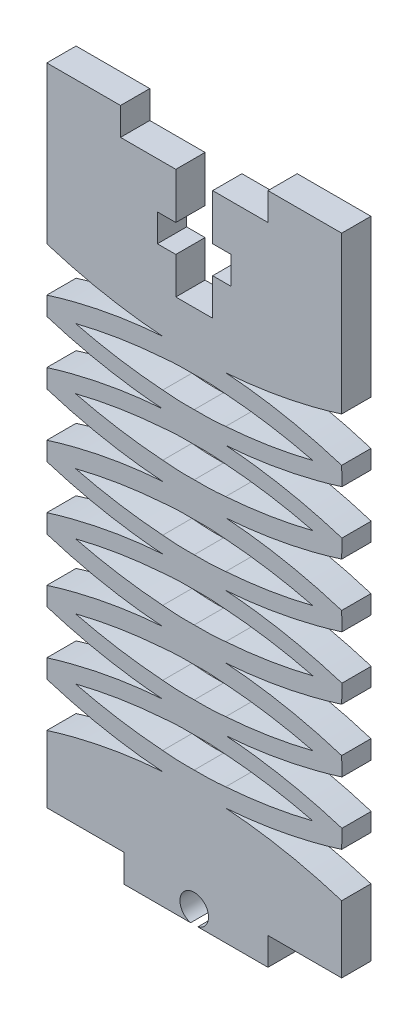
from build123d import *

# Parameters (mm, degrees)
BOSS_EXTRUDE1_DEPTH = 3.175


with BuildPart() as part:
    # Sketch1 → Boss-Extrude1 (new body)
    with BuildSketch(Plane.XY):
        with BuildLine():
            Line((0, 0), (8.370325746, 0))
            Line((8.370325746, 0), (8.370325746, -3))
            Line((8.370325746, -3), (15.609487516, -3))
            ThreePointArc((15.609487516, -3), (16, 0.05), (16.390512484, -3))
            Line((16.390512484, -3), (24, -3))
            Line((24, -3), (24, 0))
            Line((24, 0), (32, 0))
            Line((32, 0), (32, 5.370178283))
            Line((32, 5.370178283), (32, 7.265547887))
            add(Edge.make_bspline(
                [(32, 7.265547887), (27.898501415, 8.558072428), (23.69150053, 9.361273689), (19.417459256, 9.67515167)],
                knots=[0, 0, 0, 0, 0.790279221, 0.790279221, 0.790279221, 0.790279221], degree=3))
            add(Edge.make_bspline(
                [(32, 12.084755453), (27.898501415, 10.792230912), (23.69150053, 9.98902965), (19.417459256, 9.67515167)],
                knots=[0, 0, 0, 0, 0.790279221, 0.790279221, 0.790279221, 0.790279221], degree=3))
            Line((32, 12.084755453), (32.028943123, 14.084755311))
            add(Edge.make_bspline(
                [(32.028943123, 14.084755311), (27.89482684, 15.377279852), (23.690748061, 16.180481113), (19.416706786, 16.494359094)],
                knots=[0, 0, 0, 0, 0.790279221, 0.790279221, 0.790279221, 0.790279221], degree=3))
            add(Edge.make_bspline(
                [(32.028943123, 18.903962877), (27.89482684, 17.611438336), (23.690748061, 16.808237075), (19.416706786, 16.494359094)],
                knots=[0, 0, 0, 0, 0.790279221, 0.790279221, 0.790279221, 0.790279221], degree=3))
            Line((32.028943123, 18.903962877), (32, 20.903962736))
            add(Edge.make_bspline(
                [(32, 20.903962736), (27.898501415, 22.196487277), (23.69150053, 22.999688538), (19.417459256, 23.313566519)],
                knots=[0, 0, 0, 0, 0.790279221, 0.790279221, 0.790279221, 0.790279221], degree=3))
            add(Edge.make_bspline(
                [(32, 25.723170302), (27.898501415, 24.430645761), (23.69150053, 23.6274445), (19.417459256, 23.313566519)],
                knots=[0, 0, 0, 0, 0.790279221, 0.790279221, 0.790279221, 0.790279221], degree=3))
            Line((32, 25.723170302), (32.028943123, 27.72317016))
            add(Edge.make_bspline(
                [(32.028943123, 27.72317016), (27.89482684, 29.015694701), (23.690748061, 29.818895962), (19.416706786, 30.132773943)],
                knots=[0, 0, 0, 0, 0.790279221, 0.790279221, 0.790279221, 0.790279221], degree=3))
            add(Edge.make_bspline(
                [(32.028943123, 32.542377726), (27.89482684, 31.249853185), (23.690748061, 30.446651924), (19.416706786, 30.132773943)],
                knots=[0, 0, 0, 0, 0.790279221, 0.790279221, 0.790279221, 0.790279221], degree=3))
            Line((32.028943123, 32.542377726), (32, 34.542377585))
            add(Edge.make_bspline(
                [(32, 34.542377585), (27.898501415, 35.834902126), (23.69150053, 36.638103387), (19.417459256, 36.951981368)],
                knots=[0, 0, 0, 0, 0.790279221, 0.790279221, 0.790279221, 0.790279221], degree=3))
            add(Edge.make_bspline(
                [(32, 39.361585151), (27.898501415, 38.06906061), (23.69150053, 37.265859349), (19.417459256, 36.951981368)],
                knots=[0, 0, 0, 0, 0.790279221, 0.790279221, 0.790279221, 0.790279221], degree=3))
            Line((32, 39.361585151), (32.028943123, 41.361585009))
            add(Edge.make_bspline(
                [(32.028943123, 41.361585009), (27.89482684, 42.65410955), (23.690748061, 43.457310811), (19.416706786, 43.771188792)],
                knots=[0, 0, 0, 0, 0.790279221, 0.790279221, 0.790279221, 0.790279221], degree=3))
            add(Edge.make_bspline(
                [(32.028943123, 46.180792575), (27.89482684, 44.888268034), (23.690748061, 44.085066773), (19.416706786, 43.771188792)],
                knots=[0, 0, 0, 0, 0.790279221, 0.790279221, 0.790279221, 0.790279221], degree=3))
            Line((32.028943123, 46.180792575), (32, 48.180792434))
            add(Edge.make_bspline(
                [(32, 48.180792434), (27.898501415, 49.473316975), (23.69150053, 50.276518236), (19.417459256, 50.590396217)],
                knots=[0, 0, 0, 0, 0.790279221, 0.790279221, 0.790279221, 0.790279221], degree=3))
            add(Edge.make_bspline(
                [(32, 53), (27.898501415, 51.707475459), (23.69150053, 50.904274198), (19.417459256, 50.590396217)],
                knots=[0, 0, 0, 0, 0.790279221, 0.790279221, 0.790279221, 0.790279221], degree=3))
            Line((32, 53), (32, 70))
            Line((32, 70), (24, 70))
            Line((24, 70), (24, 67))
            Line((24, 67), (18, 67))
            Line((18, 67), (18, 62))
            Line((18, 62), (20, 62))
            Line((20, 62), (20, 59))
            Line((20, 59), (18, 59))
            Line((18, 59), (18, 55))
            Line((18, 55), (14, 55))
            Line((14, 55), (14, 59))
            Line((14, 59), (12, 59))
            Line((12, 59), (12, 62))
            Line((12, 62), (14, 62))
            Line((14, 62), (14, 67))
            Line((14, 67), (8, 67))
            Line((8, 67), (8, 70))
            Line((8, 70), (0, 70))
            Line((0, 70), (0, 53))
            add(Edge.make_bspline(
                [(0, 53), (4.101498585, 51.707475459), (8.30849947, 50.904274198), (12.582540744, 50.590396217)],
                knots=[0, 0, 0, 0, 0.790279221, 0.790279221, 0.790279221, 0.790279221], degree=3))
            add(Edge.make_bspline(
                [(0, 48.180792434), (4.101498585, 49.473316975), (8.30849947, 50.276518236), (12.582540744, 50.590396217)],
                knots=[0, 0, 0, 0, 0.790279221, 0.790279221, 0.790279221, 0.790279221], degree=3))
            Line((0, 48.180792434), (0, 46.171751905))
            add(Edge.make_bspline(
                [(0, 46.171751905), (3.182464098, 45.17859632), (7.360986386, 44.267141319), (11.609145024, 43.842728501), (12.583293214, 43.771188792)],
                knots=[0.001844187, 0.001844187, 0.001844187, 0.001844187, 0.610157172, 0.790279221, 0.790279221, 0.790279221, 0.790279221], degree=3))
            add(Edge.make_bspline(
                [(0, 41.37062568), (3.182464098, 42.363781265), (7.360986386, 43.275236266), (11.609145024, 43.699649084), (12.583293214, 43.771188792)],
                knots=[0.001844187, 0.001844187, 0.001844187, 0.001844187, 0.610157172, 0.790279221, 0.790279221, 0.790279221, 0.790279221], degree=3))
            Line((0, 41.37062568), (0, 39.361585151))
            add(Edge.make_bspline(
                [(0, 39.361585151), (4.101498585, 38.06906061), (8.30849947, 37.265859349), (12.582540744, 36.951981368)],
                knots=[0, 0, 0, 0, 0.790279221, 0.790279221, 0.790279221, 0.790279221], degree=3))
            add(Edge.make_bspline(
                [(0, 34.542377585), (4.101498585, 35.834902126), (8.30849947, 36.638103387), (12.582540744, 36.951981368)],
                knots=[0, 0, 0, 0, 0.790279221, 0.790279221, 0.790279221, 0.790279221], degree=3))
            Line((0, 34.542377585), (0, 32.533337056))
            add(Edge.make_bspline(
                [(0, 32.533337056), (3.182464098, 31.540181471), (7.360986386, 30.62872647), (11.609145024, 30.204313652), (12.583293214, 30.132773943)],
                knots=[0.001844187, 0.001844187, 0.001844187, 0.001844187, 0.610157172, 0.790279221, 0.790279221, 0.790279221, 0.790279221], degree=3))
            add(Edge.make_bspline(
                [(0, 27.732210831), (3.182464098, 28.725366416), (7.360986386, 29.636821417), (11.609145024, 30.061234235), (12.583293214, 30.132773943)],
                knots=[0.001844187, 0.001844187, 0.001844187, 0.001844187, 0.610157172, 0.790279221, 0.790279221, 0.790279221, 0.790279221], degree=3))
            Line((0, 27.732210831), (0, 25.723170302))
            add(Edge.make_bspline(
                [(0, 25.723170302), (4.101498585, 24.430645761), (8.30849947, 23.6274445), (12.582540744, 23.313566519)],
                knots=[0, 0, 0, 0, 0.790279221, 0.790279221, 0.790279221, 0.790279221], degree=3))
            add(Edge.make_bspline(
                [(0, 20.903962736), (4.101498585, 22.196487277), (8.30849947, 22.999688538), (12.582540744, 23.313566519)],
                knots=[0, 0, 0, 0, 0.790279221, 0.790279221, 0.790279221, 0.790279221], degree=3))
            Line((0, 20.903962736), (0, 18.894922207))
            add(Edge.make_bspline(
                [(0, 18.894922207), (3.182464098, 17.901766622), (7.360986386, 16.990311621), (11.609145024, 16.565898803), (12.583293214, 16.494359094)],
                knots=[0.001844187, 0.001844187, 0.001844187, 0.001844187, 0.610157172, 0.790279221, 0.790279221, 0.790279221, 0.790279221], degree=3))
            add(Edge.make_bspline(
                [(0, 14.093795982), (3.182464098, 15.086951567), (7.360986386, 15.998406568), (11.609145024, 16.422819386), (12.583293214, 16.494359094)],
                knots=[0.001844187, 0.001844187, 0.001844187, 0.001844187, 0.610157172, 0.790279221, 0.790279221, 0.790279221, 0.790279221], degree=3))
            Line((0, 14.093795982), (0, 12.084755453))
            add(Edge.make_bspline(
                [(0, 12.084755453), (4.101498585, 10.792230912), (8.30849947, 9.98902965), (12.582540744, 9.67515167)],
                knots=[0, 0, 0, 0, 0.790279221, 0.790279221, 0.790279221, 0.790279221], degree=3))
            add(Edge.make_bspline(
                [(0, 7.265547887), (4.101498585, 8.558072428), (8.30849947, 9.361273689), (12.582540744, 9.67515167)],
                knots=[0, 0, 0, 0, 0.790279221, 0.790279221, 0.790279221, 0.790279221], degree=3))
            Line((0, 7.265547887), (0, 0))
        make_face()
        with BuildLine():
            add(Edge.make_bspline(
                [(28.876946835, 47.068047714), (26.712893607, 47.610351012), (23.571390937, 48.20110481), (20.390854976, 48.51885665), (19.416706786, 48.590396358)],
                knots=[0.199989123, 0.199989123, 0.199989123, 0.199989123, 0.610157172, 0.790279221, 0.790279221, 0.790279221, 0.790279221], degree=3))
            add(Edge.make_bspline(
                [(19.416706786, 48.590396358), (17.713334631, 48.76927191), (16, 48.720940231)],
                knots=[0, 0, 0, 1, 1, 1], degree=2))
            add(Edge.make_bspline(
                [(12.583293214, 48.590396358), (14.286665369, 48.76927191), (16, 48.720940231)],
                knots=[0, 0, 0, 1, 1, 1], degree=2))
            add(Edge.make_bspline(
                [(3.123053165, 47.068047714), (5.287106393, 47.610351012), (8.428609063, 48.20110481), (11.609145024, 48.51885665), (12.583293214, 48.590396358)],
                knots=[0.199989123, 0.199989123, 0.199989123, 0.199989123, 0.610157172, 0.790279221, 0.790279221, 0.790279221, 0.790279221], degree=3))
            add(Edge.make_bspline(
                [(3.123053165, 47.068047714), (5.287106393, 46.525744415), (8.428609063, 45.934990617), (11.609145024, 45.617238777), (12.583293214, 45.545699069)],
                knots=[0.199989123, 0.199989123, 0.199989123, 0.199989123, 0.610157172, 0.790279221, 0.790279221, 0.790279221, 0.790279221], degree=3))
            add(Edge.make_bspline(
                [(12.583293214, 45.545699069), (14.286665369, 45.366823517), (16, 45.415155196)],
                knots=[0, 0, 0, 1, 1, 1], degree=2))
            add(Edge.make_bspline(
                [(19.416706786, 45.545699069), (17.713334631, 45.366823517), (16, 45.415155196)],
                knots=[0, 0, 0, 1, 1, 1], degree=2))
            add(Edge.make_bspline(
                [(28.876946835, 47.068047714), (26.712893607, 46.525744415), (23.571390937, 45.934990617), (20.390854976, 45.617238777), (19.416706786, 45.545699069)],
                knots=[0.199989123, 0.199989123, 0.199989123, 0.199989123, 0.610157172, 0.790279221, 0.790279221, 0.790279221, 0.790279221], degree=3))
        make_face(mode=Mode.SUBTRACT)
        with BuildLine():
            add(Edge.make_bspline(
                [(19.416706786, 41.996678516), (17.713334631, 42.175554067), (16, 42.127222389)],
                knots=[0, 0, 0, 1, 1, 1], degree=2))
            add(Edge.make_bspline(
                [(12.583293214, 41.996678516), (14.286665369, 42.175554067), (16, 42.127222389)],
                knots=[0, 0, 0, 1, 1, 1], degree=2))
            add(Edge.make_bspline(
                [(3.123054056, 40.474329642), (5.287107289, 41.016632943), (8.428608859, 41.607387016), (11.609145024, 41.925138808), (12.583293214, 41.996678516)],
                knots=[0.199989122, 0.199989122, 0.199989122, 0.199989122, 0.610157172, 0.790279221, 0.790279221, 0.790279221, 0.790279221], degree=3))
            add(Edge.make_bspline(
                [(3.123054056, 40.474329642), (5.287106992, 39.932026454), (8.428609366, 39.341272746), (11.609145024, 39.023520935), (12.583293214, 38.951981226)],
                knots=[0.199989179, 0.199989179, 0.199989179, 0.199989179, 0.610157172, 0.790279221, 0.790279221, 0.790279221, 0.790279221], degree=3))
            add(Edge.make_bspline(
                [(12.583293214, 38.951981226), (14.286665369, 38.773105675), (16, 38.821437353)],
                knots=[0, 0, 0, 1, 1, 1], degree=2))
            add(Edge.make_bspline(
                [(19.416706786, 38.951981226), (17.713334631, 38.773105675), (16, 38.821437353)],
                knots=[0, 0, 0, 1, 1, 1], degree=2))
            add(Edge.make_bspline(
                [(28.876945944, 40.474329642), (26.712893008, 39.932026454), (23.571390634, 39.341272746), (20.390854976, 39.023520935), (19.416706786, 38.951981226)],
                knots=[0.199989179, 0.199989179, 0.199989179, 0.199989179, 0.610157172, 0.790279221, 0.790279221, 0.790279221, 0.790279221], degree=3))
            add(Edge.make_bspline(
                [(28.876945944, 40.474329642), (26.712892711, 41.016632943), (23.571391141, 41.607387016), (20.390854976, 41.925138808), (19.416706786, 41.996678516)],
                knots=[0.199989122, 0.199989122, 0.199989122, 0.199989122, 0.610157172, 0.790279221, 0.790279221, 0.790279221, 0.790279221], degree=3))
        make_face(mode=Mode.SUBTRACT)
        with BuildLine():
            add(Edge.make_bspline(
                [(19.416706786, 31.90728422), (17.713334631, 31.728408668), (16, 31.776740347)],
                knots=[0, 0, 0, 1, 1, 1], degree=2))
            add(Edge.make_bspline(
                [(12.583293214, 31.90728422), (14.286665369, 31.728408668), (16, 31.776740347)],
                knots=[0, 0, 0, 1, 1, 1], degree=2))
            add(Edge.make_bspline(
                [(3.123054056, 33.429633093), (5.287107289, 32.887329792), (8.428608859, 32.296575719), (11.609145024, 31.978823928), (12.583293214, 31.90728422)],
                knots=[0.199989122, 0.199989122, 0.199989122, 0.199989122, 0.610157172, 0.790279221, 0.790279221, 0.790279221, 0.790279221], degree=3))
            add(Edge.make_bspline(
                [(3.123054056, 33.429633093), (5.287106992, 33.971936281), (8.428609366, 34.56268999), (11.609145024, 34.880441801), (12.583293214, 34.951981509)],
                knots=[0.199989179, 0.199989179, 0.199989179, 0.199989179, 0.610157172, 0.790279221, 0.790279221, 0.790279221, 0.790279221], degree=3))
            add(Edge.make_bspline(
                [(12.583293214, 34.951981509), (14.286665369, 35.130857061), (16, 35.082525382)],
                knots=[0, 0, 0, 1, 1, 1], degree=2))
            add(Edge.make_bspline(
                [(19.416706786, 34.951981509), (17.713334631, 35.130857061), (16, 35.082525382)],
                knots=[0, 0, 0, 1, 1, 1], degree=2))
            add(Edge.make_bspline(
                [(28.876945944, 33.429633093), (26.712893008, 33.971936281), (23.571390634, 34.56268999), (20.390854976, 34.880441801), (19.416706786, 34.951981509)],
                knots=[0.199989179, 0.199989179, 0.199989179, 0.199989179, 0.610157172, 0.790279221, 0.790279221, 0.790279221, 0.790279221], degree=3))
            add(Edge.make_bspline(
                [(28.876945944, 33.429633093), (26.712892711, 32.887329792), (23.571391141, 32.296575719), (20.390854976, 31.978823928), (19.416706786, 31.90728422)],
                knots=[0.199989122, 0.199989122, 0.199989122, 0.199989122, 0.610157172, 0.790279221, 0.790279221, 0.790279221, 0.790279221], degree=3))
        make_face(mode=Mode.SUBTRACT)
        with BuildLine():
            add(Edge.make_bspline(
                [(19.416706786, 28.358263667), (17.713334631, 28.537139218), (16, 28.48880754)],
                knots=[0, 0, 0, 1, 1, 1], degree=2))
            add(Edge.make_bspline(
                [(12.583293214, 28.358263667), (14.286665369, 28.537139218), (16, 28.48880754)],
                knots=[0, 0, 0, 1, 1, 1], degree=2))
            add(Edge.make_bspline(
                [(3.123054056, 26.835914793), (5.287107289, 27.378218094), (8.428608859, 27.968972167), (11.609145024, 28.286723958), (12.583293214, 28.358263667)],
                knots=[0.199989122, 0.199989122, 0.199989122, 0.199989122, 0.610157172, 0.790279221, 0.790279221, 0.790279221, 0.790279221], degree=3))
            add(Edge.make_bspline(
                [(3.123054056, 26.835914793), (5.287106992, 26.293611605), (8.428609366, 25.702857897), (11.609145024, 25.385106086), (12.583293214, 25.313566377)],
                knots=[0.199989179, 0.199989179, 0.199989179, 0.199989179, 0.610157172, 0.790279221, 0.790279221, 0.790279221, 0.790279221], degree=3))
            add(Edge.make_bspline(
                [(12.583293214, 25.313566377), (14.286665369, 25.134690826), (16, 25.183022504)],
                knots=[0, 0, 0, 1, 1, 1], degree=2))
            add(Edge.make_bspline(
                [(19.416706786, 25.313566377), (17.713334631, 25.134690826), (16, 25.183022504)],
                knots=[0, 0, 0, 1, 1, 1], degree=2))
            add(Edge.make_bspline(
                [(28.876945944, 26.835914793), (26.712893008, 26.293611605), (23.571390634, 25.702857897), (20.390854976, 25.385106086), (19.416706786, 25.313566377)],
                knots=[0.199989179, 0.199989179, 0.199989179, 0.199989179, 0.610157172, 0.790279221, 0.790279221, 0.790279221, 0.790279221], degree=3))
            add(Edge.make_bspline(
                [(28.876945944, 26.835914793), (26.712892711, 27.378218094), (23.571391141, 27.968972167), (20.390854976, 28.286723958), (19.416706786, 28.358263667)],
                knots=[0.199989122, 0.199989122, 0.199989122, 0.199989122, 0.610157172, 0.790279221, 0.790279221, 0.790279221, 0.790279221], degree=3))
        make_face(mode=Mode.SUBTRACT)
        with BuildLine():
            add(Edge.make_bspline(
                [(19.416706786, 21.31356666), (17.713334631, 21.492442212), (16, 21.444110533)],
                knots=[0, 0, 0, 1, 1, 1], degree=2))
            add(Edge.make_bspline(
                [(12.583293214, 21.31356666), (14.286665369, 21.492442212), (16, 21.444110533)],
                knots=[0, 0, 0, 1, 1, 1], degree=2))
            add(Edge.make_bspline(
                [(3.123054056, 19.791218244), (5.287106992, 20.333521432), (8.428609366, 20.924275141), (11.609145024, 21.242026952), (12.583293214, 21.31356666)],
                knots=[0.199989179, 0.199989179, 0.199989179, 0.199989179, 0.610157172, 0.790279221, 0.790279221, 0.790279221, 0.790279221], degree=3))
            add(Edge.make_bspline(
                [(3.123054056, 19.791218244), (5.287107289, 19.248914943), (8.428608859, 18.65816087), (11.609145024, 18.340409079), (12.583293214, 18.26886937)],
                knots=[0.199989122, 0.199989122, 0.199989122, 0.199989122, 0.610157172, 0.790279221, 0.790279221, 0.790279221, 0.790279221], degree=3))
            add(Edge.make_bspline(
                [(12.583293214, 18.26886937), (14.286665369, 18.089993819), (16, 18.138325498)],
                knots=[0, 0, 0, 1, 1, 1], degree=2))
            add(Edge.make_bspline(
                [(19.416706786, 18.26886937), (17.713334631, 18.089993819), (16, 18.138325498)],
                knots=[0, 0, 0, 1, 1, 1], degree=2))
            add(Edge.make_bspline(
                [(28.876945944, 19.791218244), (26.712892711, 19.248914943), (23.571391141, 18.65816087), (20.390854976, 18.340409079), (19.416706786, 18.26886937)],
                knots=[0.199989122, 0.199989122, 0.199989122, 0.199989122, 0.610157172, 0.790279221, 0.790279221, 0.790279221, 0.790279221], degree=3))
            add(Edge.make_bspline(
                [(28.876945944, 19.791218244), (26.712893008, 20.333521432), (23.571390634, 20.924275141), (20.390854976, 21.242026952), (19.416706786, 21.31356666)],
                knots=[0.199989179, 0.199989179, 0.199989179, 0.199989179, 0.610157172, 0.790279221, 0.790279221, 0.790279221, 0.790279221], degree=3))
        make_face(mode=Mode.SUBTRACT)
        with BuildLine():
            add(Edge.make_bspline(
                [(3.123054056, 13.197499944), (5.287107289, 13.739803245), (8.428608859, 14.330557318), (11.609145024, 14.648309109), (12.583293214, 14.719848818)],
                knots=[0.199989122, 0.199989122, 0.199989122, 0.199989122, 0.610157172, 0.790279221, 0.790279221, 0.790279221, 0.790279221], degree=3))
            add(Edge.make_bspline(
                [(12.583293214, 14.719848818), (14.286665369, 14.898724369), (16, 14.850392691)],
                knots=[0, 0, 0, 1, 1, 1], degree=2))
            add(Edge.make_bspline(
                [(19.416706786, 14.719848818), (17.713334631, 14.898724369), (16, 14.850392691)],
                knots=[0, 0, 0, 1, 1, 1], degree=2))
            add(Edge.make_bspline(
                [(28.876945944, 13.197499944), (26.712892711, 13.739803245), (23.571391141, 14.330557318), (20.390854976, 14.648309109), (19.416706786, 14.719848818)],
                knots=[0.199989122, 0.199989122, 0.199989122, 0.199989122, 0.610157172, 0.790279221, 0.790279221, 0.790279221, 0.790279221], degree=3))
            add(Edge.make_bspline(
                [(28.876945944, 13.197499944), (26.712893008, 12.655196756), (23.571390634, 12.064443047), (20.390854976, 11.746691237), (19.416706786, 11.675151528)],
                knots=[0.199989179, 0.199989179, 0.199989179, 0.199989179, 0.610157172, 0.790279221, 0.790279221, 0.790279221, 0.790279221], degree=3))
            add(Edge.make_bspline(
                [(19.416706786, 11.675151528), (17.713334631, 11.496275977), (16, 11.544607655)],
                knots=[0, 0, 0, 1, 1, 1], degree=2))
            add(Edge.make_bspline(
                [(12.583293214, 11.675151528), (14.286665369, 11.496275977), (16, 11.544607655)],
                knots=[0, 0, 0, 1, 1, 1], degree=2))
            add(Edge.make_bspline(
                [(3.123054056, 13.197499944), (5.287106992, 12.655196756), (8.428609366, 12.064443047), (11.609145024, 11.746691237), (12.583293214, 11.675151528)],
                knots=[0.199989179, 0.199989179, 0.199989179, 0.199989179, 0.610157172, 0.790279221, 0.790279221, 0.790279221, 0.790279221], degree=3))
        make_face(mode=Mode.SUBTRACT)
    extrude(amount=BOSS_EXTRUDE1_DEPTH)


solid = part.part
